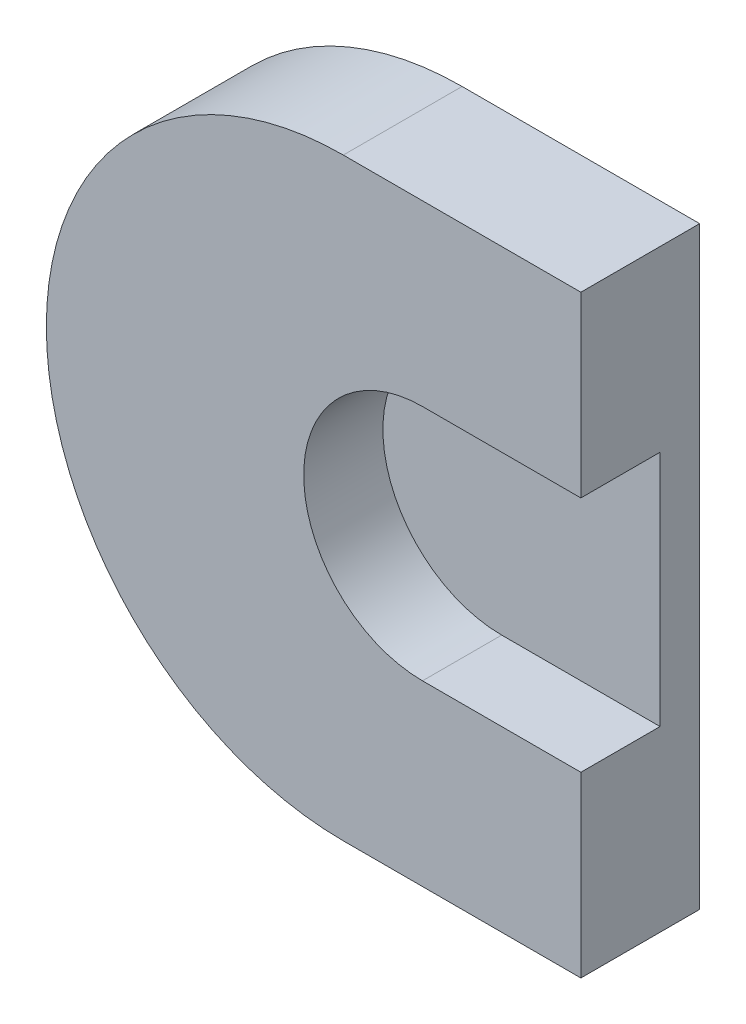
from build123d import *

# Parameters (mm, degrees)
EXTRUDE_1_DEPTH     = 3
CUT_EXTRUDE_1_DEPTH = 2


with BuildPart() as part:
    # Эскиз1 → Бобышка-Вытянуть1 (new body)
    with BuildSketch(Plane.XY):
        with BuildLine():
            Line((0, 7.5), (6, 7.5))
            Line((6, 7.5), (6, -7.5))
            Line((6, -7.5), (0, -7.5))
            ThreePointArc((0, -7.5), (-7.5, 0), (0, 7.5))
        make_face()
    extrude(amount=EXTRUDE_1_DEPTH)

    # Эскиз2 → Вырез-Вытянуть1 (cut)
    with BuildSketch(Plane.XY.offset(3)):
        with BuildLine():
            Line((6, -3), (2, -3))
            ThreePointArc((2, -3), (-1, 0), (2, 3))
            Line((2, 3), (6, 3))
            ThreePointArc((6, 3), (9, 0), (6, -3))
        make_face()
    extrude(amount=-CUT_EXTRUDE_1_DEPTH, mode=Mode.SUBTRACT)


solid = part.part
